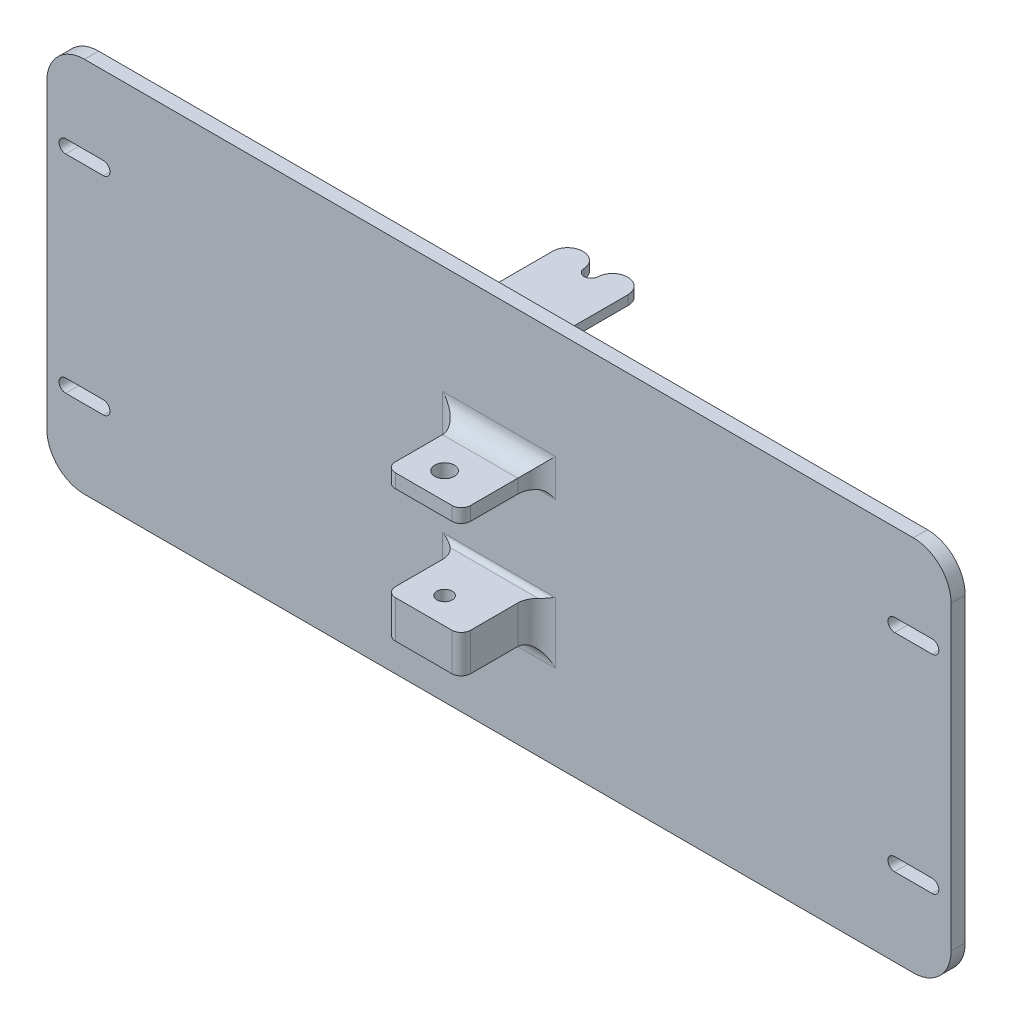
from build123d import *

# Parameters (mm, degrees)
SKETCH1_W                            = 304.8
SKETCH1_H                            = 127
BOSS_EXTRUDE1_DEPTH                  = 4.7625
SKETCH2_W                            = 25.4
SKETCH2_H                            = 3.175
BOSS_EXTRUDE2_DEPTH                  = 31.115
CUT_EXTRUDE1_DEPTH                   = 63.5
FILLET1_R                            = 5.08
FILLET2_R                            = 12.7
FILLET4_R                            = 6.35
CUT_EXTRUDE2_DEPTH                   = 4.7625
LPATTERN2_COUNT                      = 2
LPATTERN2_PITCH                      = 279.4
LPATTERN2_COUNT_DIR2                 = 2
LPATTERN2_PITCH_DIR2                 = 69.85
SKETCH8_W                            = 25.4
SKETCH8_H                            = 12.7
SKETCH8_H_2                          = 4.6355
BOSS_EXTRUDE3_DEPTH                  = 25.4
CUT_EXTRUDE3_REACH                   = 86.087
SKETCH9_R                            = 3.302
F_13_64_0_20313_DIAMETER_HOLE1_D     = 5.159502
F_13_64_0_20313_DIAMETER_HOLE1_DEPTH = 9.0678
F_13_64_0_20313_DIAMETER_HOLE1_TIP   = 1.550070783
FILLET5_R                            = 6.35
FILLET6_R                            = 3.175
FILLET7_R                            = 1.5875
FILLET11_R                           = 6.35


with BuildPart() as part:
    # Sketch1 → Boss-Extrude1 (new body)
    with BuildSketch(Plane.XY):
        Rectangle(SKETCH1_W, SKETCH1_H)
    extrude(amount=BOSS_EXTRUDE1_DEPTH)

    # Sketch2 → Boss-Extrude2 (add)
    with BuildSketch(Plane(origin=(0, 0, 0), x_dir=(-1, 0, 0), z_dir=(0, 0, -1))):
        with Locations((0, 53.975)):
            Rectangle(SKETCH2_W, SKETCH2_H)
        with Locations((0, -53.975)):
            Rectangle(SKETCH2_W, SKETCH2_H)
    extrude(amount=BOSS_EXTRUDE2_DEPTH)

    # Sketch3 → Cut-Extrude1 (cut, symmetric)
    with BuildSketch(Plane(origin=(0, 0, 0), x_dir=(1, 0, 0), z_dir=(0, 1, 0))):
        with BuildLine():
            Line((2.38125, 26.3525), (2.38125, 31.115))
            Line((2.38125, 31.115), (-2.38125, 31.115))
            Line((-2.38125, 31.115), (-2.38125, 26.3525))
            ThreePointArc((-2.38125, 26.3525), (0, 23.97125), (2.38125, 26.3525))
        make_face()
    extrude(amount=CUT_EXTRUDE1_DEPTH, both=True, mode=Mode.SUBTRACT)

    # Fillet1
    fillet1_edges = [part.edges().sort_by_distance(p)[0] for p in [
        (-2.38125, -53.975, -31.115),
        (2.38125, -53.975, -31.115),
        (-2.38125, 53.975, -31.115),
        (2.38125, 53.975, -31.115),
        (12.7, -53.975, -31.115),
        (-12.7, -53.975, -31.115),
        (-12.7, 53.975, -31.115),
        (12.7, 53.975, -31.115),
    ]]
    fillet(fillet1_edges, radius=FILLET1_R)

    # Fillet2
    fillet2_edges = [part.edges().sort_by_distance(p)[0] for p in [
        (-152.4, 63.5, 2.38125),
        (152.4, 63.5, 2.38125),
        (152.4, -63.5, 2.38125),
        (-152.4, -63.5, 2.38125),
    ]]
    fillet(fillet2_edges, radius=FILLET2_R)

    # Fillet4
    fillet4_edges = [part.edges().sort_by_distance(p)[0] for p in [
        (12.7, 53.975, 0),
        (0, 52.3875, 0),
        (-12.7, 53.975, 0),
        (0, 55.5625, 0),
        (0, -52.3875, 0),
        (12.7, -53.975, 0),
        (0, -55.5625, 0),
        (-12.7, -53.975, 0),
    ]]
    fillet(fillet4_edges, radius=FILLET4_R)

    # Sketch7 → Cut-Extrude2 (cut)
    with BuildSketch(Plane(origin=(0, 0, 0), x_dir=(-1, 0, 0), z_dir=(0, 0, -1))):
        with BuildLine():
            Line((-146.05, 37.1475), (-133.35, 37.1475))
            ThreePointArc((-133.35, 37.1475), (-131.1275, 34.925), (-133.35, 32.7025))
            Line((-133.35, 32.7025), (-146.05, 32.7025))
            ThreePointArc((-146.05, 32.7025), (-148.2725, 34.925), (-146.05, 37.1475))
        make_face()
    cut_extrude2 = extrude(amount=-CUT_EXTRUDE2_DEPTH, mode=Mode.SUBTRACT)

    # LPattern2: Cut-Extrude2 2 × 2
    with Locations(*[(-i * LPATTERN2_PITCH, -j * LPATTERN2_PITCH_DIR2, 0) for i in range(LPATTERN2_COUNT) for j in range(LPATTERN2_COUNT_DIR2) if (i, j) != (0, 0)]):
        add(cut_extrude2, mode=Mode.SUBTRACT)

    # Sketch8 → Boss-Extrude3 (add)
    with BuildSketch(Plane.XY.offset(4.7625)):
        with Locations((0, -22.19325)):
            Rectangle(SKETCH8_W, SKETCH8_H)
        with Locations((0, 18.26895)):
            Rectangle(SKETCH8_W, SKETCH8_H_2)
    extrude(amount=BOSS_EXTRUDE3_DEPTH)

    # Sketch9 → Cut-Extrude3 (cut, up to next)
    with BuildSketch(Plane(origin=(0, 20.5867, 0), x_dir=(1, 0, 0), z_dir=(0, 1, 0)), mode=Mode.PRIVATE) as cut_extrude3_sk1:
        with Locations(Location((-1.812874351, -21.2725, 0), (0, 0, 270))):  # turned: the seam where the file's is
            Circle(SKETCH9_R)
    cut_extrude3_tool1 = extrude(cut_extrude3_sk1.sketch, amount=-CUT_EXTRUDE3_REACH, mode=Mode.PRIVATE) & part.part
    add(cut_extrude3_tool1.solids().sort_by_distance((-1.812874, 20.5867, 21.2725))[0], mode=Mode.SUBTRACT)

    # 13/64 (0.20313) Diameter Hole1
    with Locations(Plane(origin=(0, -15.84325, 0), x_dir=(-1, 0, 0), z_dir=(0, 1, 0))):
        with Locations((1.812886138, 21.2725)):
            Hole(F_13_64_0_20313_DIAMETER_HOLE1_D / 2, depth=F_13_64_0_20313_DIAMETER_HOLE1_DEPTH)
            with Locations((0, 0, -(F_13_64_0_20313_DIAMETER_HOLE1_DEPTH + F_13_64_0_20313_DIAMETER_HOLE1_TIP / 2))):  # 118° drill point
                Cone(0, F_13_64_0_20313_DIAMETER_HOLE1_D / 2, F_13_64_0_20313_DIAMETER_HOLE1_TIP, mode=Mode.SUBTRACT)

    # Fillet5
    fillet5_edges = [part.edges().sort_by_distance(p)[0] for p in [
        (-12.7, -22.19325, 4.7625),
        (12.7, -22.19325, 4.7625),
        (-12.7, 18.26895, 4.7625),
        (12.7, 18.26895, 4.7625),
    ]]
    fillet(fillet5_edges, radius=FILLET5_R)

    # Fillet6
    fillet6_edges = [part.edges().sort_by_distance(p)[0] for p in [
        (-12.7, -22.19325, 30.1625),
        (12.7, -22.19325, 30.1625),
        (-12.7, 18.26895, 30.1625),
        (12.7, 18.26895, 30.1625),
    ]]
    fillet(fillet6_edges, radius=FILLET6_R)

    # Fillet7
    fillet7_edges = [part.edges().sort_by_distance(p)[0] for p in [
        (0, -15.84325, 4.7625),
        (0, 15.9512, 4.7625),
    ]]
    fillet(fillet7_edges, radius=FILLET7_R)

    # Fillet11
    fillet11_edges = [part.edges().sort_by_distance(p)[0] for p in [
        (0, -28.54325, 4.7625),
        (0, 20.5867, 4.7625),
    ]]
    fillet(fillet11_edges, radius=FILLET11_R)


solid = part.part
